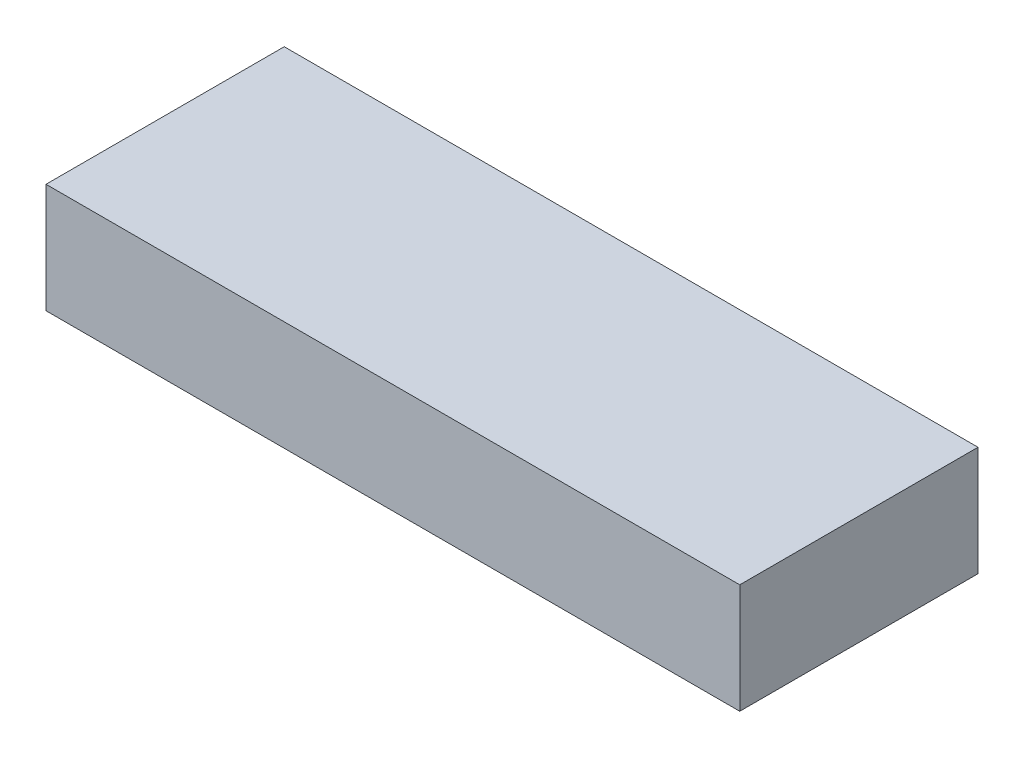
from build123d import *

# Parameters (mm, degrees)
SKETCH1_W           = 19.304
SKETCH1_H           = 6.6294
BOSS_EXTRUDE1_DEPTH = 3.048


with BuildPart() as part:
    # Sketch1 → Boss-Extrude1 (new body)
    with BuildSketch(Plane(origin=(0, 0, 0), x_dir=(1, 0, 0), z_dir=(0, 1, 0))):
        with Locations((9.652, 3.3147)):
            Rectangle(SKETCH1_W, SKETCH1_H)
    extrude(amount=BOSS_EXTRUDE1_DEPTH)


solid = part.part
